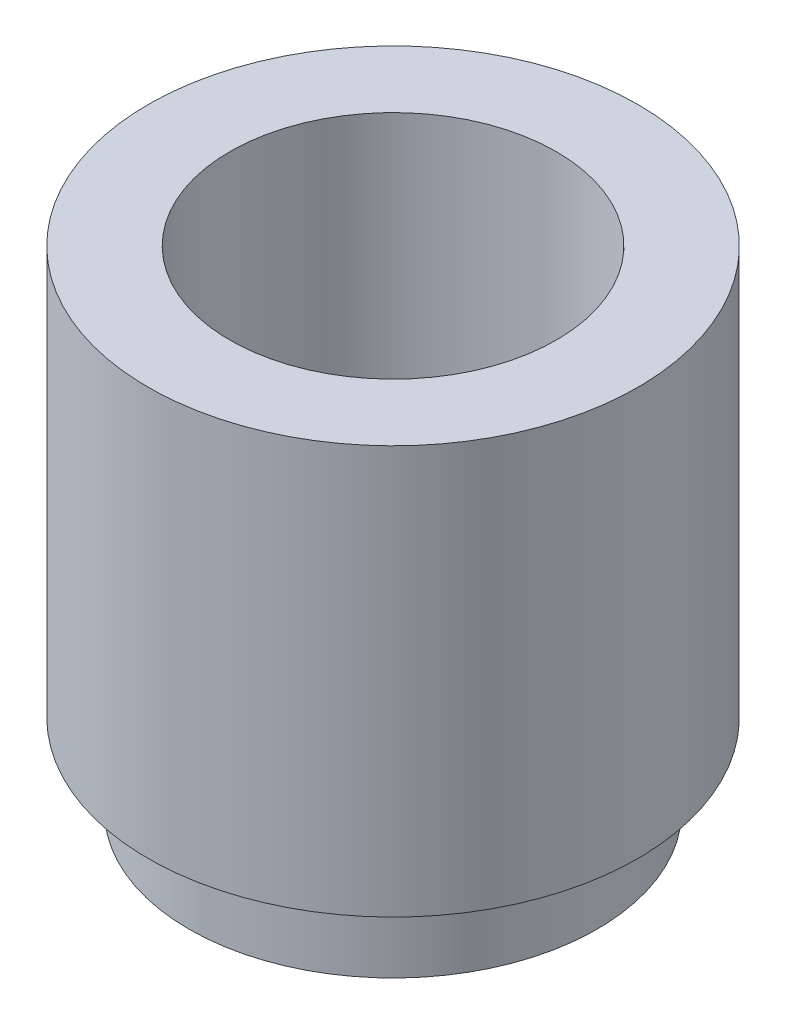
from build123d import *


with BuildPart() as part:
    # Sketch1 → Revolve1 (revolve)
    with BuildSketch(Plane(origin=(0, 0, 0), x_dir=(0, 0, -1), z_dir=(1, 0, 0))):
        Polygon((2, 6), (2, 0), (2.5, 0), (2.5, 1), (3, 1), (3, 6), align=None)
    revolve(axis=Axis((0, 0, 0), (0, 1, 0)))


solid = part.part
